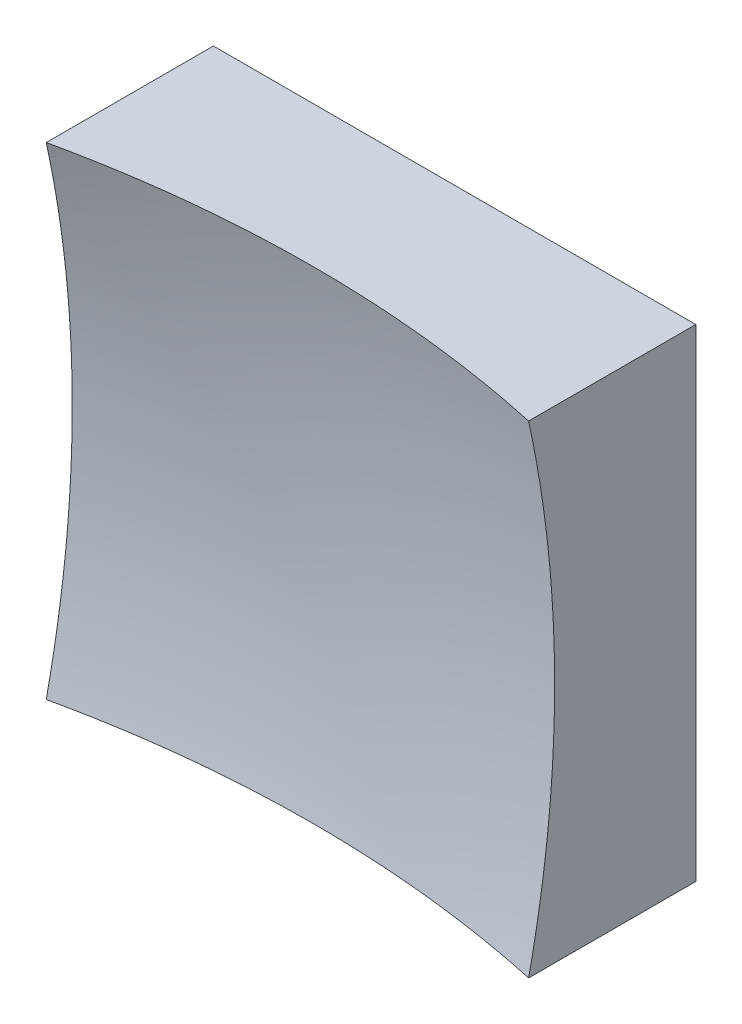
from build123d import *

# Parameters (mm, degrees)
SKETCH_1_W      = 25
SKETCH_1_H      = 25
EXTRUDE_1_DEPTH = 20


with BuildPart() as part:
    # 草图1 → 凸台-拉伸1 (new body)
    with BuildSketch(Plane.XY):
        Rectangle(SKETCH_1_W, SKETCH_1_H)
    extrude(amount=EXTRUDE_1_DEPTH)

    # 草图2 → 切除-旋转2 (revolve, cut)
    with BuildSketch(Plane(origin=(0, 0, 0), x_dir=(1, 0, 0), z_dir=(0, 1, 0))):
        with BuildLine():
            Line((58.490727709, -52.627088122), (0, -52.627088122))
            Line((0, -52.627088122), (0, -6))
            ThreePointArc((0, -6), (37.400703786, -19.083186848), (58.490727709, -52.627088122))
        make_face()
    revolve(axis=Axis((0, 0, 52.627088122), (0, 0, -1)), mode=Mode.SUBTRACT)


solid = part.part
